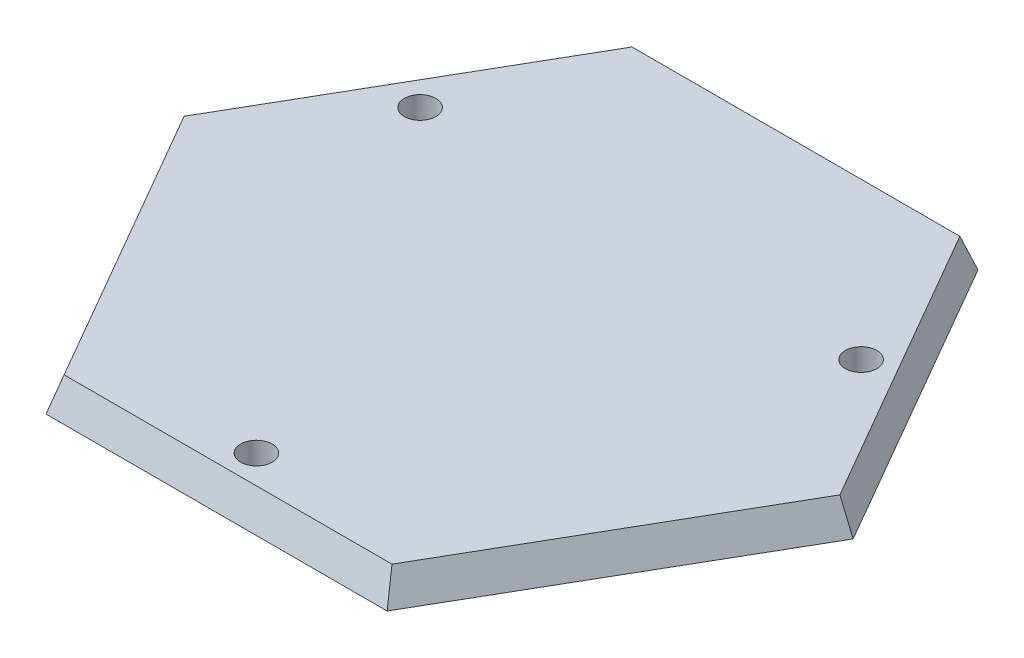
from build123d import *

# Parameters (mm, degrees)
BOSS_EXTRUDE1_DEPTH = 10
BOSS_EXTRUDE1_TAPER = -20
SKETCH1_4_R         = 5
CUT_EXTRUDE1_DEPTH  = 10


with BuildPart() as part:
    # Sketch1 → Boss-Extrude1 (new body)
    with BuildSketch(Plane(origin=(0, 0, 0), x_dir=(1, 0, 0), z_dir=(0, 1, 0))):
        Polygon((103.923048454, 0), (51.961524227, 90), (-51.961524227, 90), (-103.923048454, 0), (-51.961524227, -90), (51.961524227, -90), align=None)
    extrude(amount=-BOSS_EXTRUDE1_DEPTH, taper=BOSS_EXTRUDE1_TAPER)

    # Sketch1_4 → Cut-Extrude1 (cut)
    with BuildSketch(Plane(origin=(0, 0, 0), x_dir=(1, 0, 0), z_dir=(0, 1, 0))):
        with Locations((0, -81)):
            Circle(SKETCH1_4_R)
        with Locations((70.148057707, 40.5)):
            Circle(SKETCH1_4_R)
        with Locations((-68.942286341, 39.803847577)):
            Circle(SKETCH1_4_R)
    extrude(amount=-CUT_EXTRUDE1_DEPTH, mode=Mode.SUBTRACT)


solid = part.part
